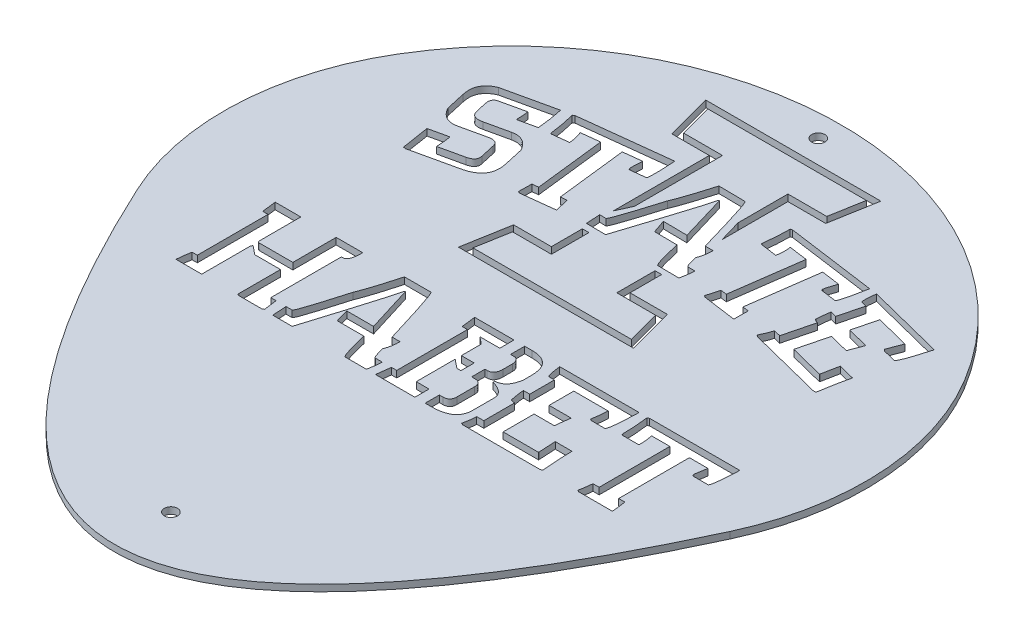
from build123d import *

# Parameters (mm, degrees)
BOSS_EXTRUDE1_DEPTH   = 1.27
FILLET1_R             = 50.8
HABET_TEXT_DEPTH      = 2.54
STATE_LOGO_1_DEPTH    = 2.54
STATE_LOGO_2_DEPTH    = 2.54
SKETCH5_R             = 1.27
MOUNT_HOLES_DEPTH     = 2.54
LETTER_TOUCHUPS_DEPTH = 1.27


with BuildPart() as part:
    # Sketch1 → Boss-Extrude1 (new body)
    with BuildSketch(Plane(origin=(0, 0, 0), x_dir=(1, 0, 0), z_dir=(0, 1, 0))):
        with BuildLine():
            ThreePointArc((105.41, 0), (41.91, 63.5), (-21.59, 0))
            add(Edge.make_bspline(
                [(-21.59, 0), (41.91, -152.4), (105.41, 0)],
                knots=[0, 0, 0, 1, 1, 1], degree=2))
        make_face()
    extrude(amount=BOSS_EXTRUDE1_DEPTH)

    # Fillet1
    fillet1_edges = [part.edges().sort_by_distance(p)[0] for p in [
        (105.41, 0.635, 0),
        (-21.59, 0.635, 0),
    ]]
    fillet(fillet1_edges, radius=FILLET1_R)

    # Sketch2 → HABET text (cut)
    with BuildSketch(Plane(origin=(0, 1.27, 0), x_dir=(1, 0, 0), z_dir=(0, 1, 0))):
        with BuildLine():
            Line((0.321789747, -3.776283493), (5.256736985, -3.776283493))
            Line((5.256736985, -3.776283493), (5.256736985, -11.769952021))
            add(Edge.make_bspline(
                [(5.256736985, -11.769952021), (5.276665661, -11.854790905), (5.324891876, -12.046060769), (5.511513222, -12.109993559), (5.591777333, -12.104992369)],
                knots=[0, 0, 0, 0, 0.531818286, 1, 1, 1, 1], degree=3))
            Line((5.591777333, -12.104992369), (12.056085216, -12.104992369))
            Line((12.056085216, -12.104992369), (12.056085216, -3.776283493))
            Line((12.056085216, -3.776283493), (17.164465104, -3.776283493))
            add(Edge.make_bspline(
                [(17.164465104, -3.776283493), (17.160143723, -4.174152873), (17.149808616, -4.734801136), (17.030648999, -5.415323619), (16.926195937, -5.80555091), (16.781923581, -6.109760812), (16.558088613, -6.405751765), (16.303749506, -6.506731746), (16.139635806, -6.503906087)],
                knots=[0, 0, 0, 0, 0.377825297, 0.528227417, 0.653887922, 0.759095955, 0.845793776, 1, 1, 1, 1], degree=3))
            Line((16.139635806, -6.503906087), (15.808537109, -6.503906087))
            Line((15.808537109, -6.503906087), (15.808537109, -20.098660898))
            Line((15.808537109, -20.098660898), (16.817599803, -20.098660898))
            add(Edge.make_bspline(
                [(16.817599803, -20.098660898), (16.81400749, -20.205888718), (16.841743547, -20.391521), (16.863462544, -20.676217018), (16.908505481, -20.9682663), (16.951195354, -21.314826269), (17.048718716, -21.880849288), (17.103583201, -22.335258896), (17.164465104, -22.652850842)],
                knots=[0, 0, 0, 0, 0.124227694, 0.217909618, 0.332038768, 0.467782146, 0.624074868, 1, 1, 1, 1], degree=3))
            Line((17.164465104, -22.652850842), (16.817599803, -22.826283493))
            Line((16.817599803, -22.826283493), (12.402950517, -22.826283493))
            add(Edge.make_bspline(
                [(12.402950517, -22.826283493), (12.317963623, -22.823811689), (12.097342761, -22.785025948), (12.05855702, -22.564405085), (12.056085216, -22.479418192)],
                knots=[0, 0, 0, 0, 0.5, 1, 1, 1, 1], degree=3))
            Line((12.056085216, -22.479418192), (12.056085216, -14.485749663))
            Line((12.056085216, -14.485749663), (7.121137978, -14.485749663))
            Line((7.121137978, -14.485749663), (5.430169636, -13.129821668))
            Line((5.430169636, -13.129821668), (5.256736985, -13.472745318))
            Line((5.256736985, -13.472745318), (5.256736985, -22.826283493))
            Line((5.256736985, -22.826283493), (0.321789747, -22.826283493))
            add(Edge.make_bspline(
                [(0.321789747, -22.826283493), (0.31645231, -22.671888101), (0.342834985, -22.424157171), (0.367003888, -22.067431584), (0.410908223, -21.746221323), (0.454724562, -21.385356188), (0.549119029, -20.83326951), (0.60736443, -20.397699329), (0.668655048, -20.098660898)],
                knots=[0, 0, 0, 0, 0.167857211, 0.271328623, 0.38963404, 0.521086911, 0.667536674, 1, 1, 1, 1], degree=3))
            Line((0.668655048, -20.098660898), (1.677717742, -20.098660898))
            Line((1.677717742, -20.098660898), (1.677717742, -6.503906087))
            Line((1.677717742, -6.503906087), (0.668655048, -6.503906087))
            add(Edge.make_bspline(
                [(0.668655048, -6.503906087), (0.608512822, -6.14398303), (0.553976204, -5.633282549), (0.456111496, -5.001477245), (0.413245992, -4.626120543), (0.368300279, -4.319582403), (0.347599895, -4.042730446), (0.319907176, -3.870322246), (0.321789747, -3.776283493)],
                knots=[0, 0, 0, 0, 0.397879084, 0.56002599, 0.697260921, 0.809964686, 0.897811149, 1, 1, 1, 1], degree=3))
        make_face()
        with BuildLine():
            Line((25.201491796, -3.788108446), (30.298046731, -3.788108446))
            add(Edge.make_bspline(
                [(30.298046731, -3.788108446), (30.366108127, -3.82479978), (30.436259495, -3.969338582), (30.548805268, -4.207612289), (30.672864093, -4.517281641), (30.821141387, -4.912112525), (31.000971498, -5.392688258), (31.193909996, -5.963520917), (31.417187781, -6.619626865), (31.658631144, -7.36469643), (31.933856353, -8.195801399), (32.222169546, -9.117039237), (32.538277645, -10.12494744), (32.882604334, -11.218169004), (33.380106407, -12.85532437), (33.77613151, -14.123269161), (34.034732019, -15.002105963)],
                knots=[0, 0, 0, 0, 0.018772946, 0.039326689, 0.067393185, 0.103005763, 0.146294354, 0.197354176, 0.255675461, 0.321892548, 0.395794966, 0.477496108, 0.566465293, 0.66343768, 0.76789845, 1, 1, 1, 1], degree=3))
            Line((34.034732019, -15.002105963), (35.564092665, -15.002105963))
            Line((35.564092665, -15.002105963), (35.564092665, -15.175538614))
            add(Edge.make_bspline(
                [(35.564092665, -15.175538614), (35.564803594, -15.648317662), (35.485635336, -16.575658132), (35.229848591, -17.470772068), (35.059561318, -17.891336255)],
                knots=[0, 0, 0, 0, 0.510453896, 1, 1, 1, 1], degree=3))
            add(Edge.make_bspline(
                [(35.059561318, -17.891336255), (35.135555264, -18.217900936), (35.265037045, -18.667915366), (35.431919653, -19.222203774), (35.54248004, -19.534768314), (35.641471172, -19.781208347), (35.748244999, -19.978992939), (35.832677069, -20.097695224), (35.910957966, -20.110485851)],
                knots=[0, 0, 0, 0, 0.415940519, 0.581562715, 0.71828315, 0.827951039, 0.909707124, 1, 1, 1, 1], degree=3))
            Line((35.910957966, -20.110485851), (37.266885961, -20.110485851))
            add(Edge.make_bspline(
                [(37.266885961, -20.110485851), (37.268121053, -20.261851817), (37.254175147, -20.507942151), (37.219517494, -20.861145434), (37.178731718, -21.18276862), (37.132628168, -21.54182206), (37.048659783, -22.093970448), (36.974167944, -22.525451161), (36.923962311, -22.826283493)],
                knots=[0, 0, 0, 0, 0.165637154, 0.269704192, 0.38854274, 0.52058799, 0.666056666, 1, 1, 1, 1], degree=3))
            Line((36.923962311, -22.826283493), (32.852236675, -22.826283493))
            add(Edge.make_bspline(
                [(32.852236675, -22.826283493), (32.797367163, -22.821835429), (32.728002071, -22.753372797), (32.645989727, -22.630805165), (32.569328789, -22.48407748), (32.4826095, -22.299312461), (32.392041375, -22.072858267), (32.299689146, -21.804776172), (32.196153456, -21.496316819), (32.087321891, -21.146303465), (31.967515127, -20.755585404), (31.846649167, -20.32286006), (31.720689432, -19.848131181), (31.58746859, -19.332877021), (31.389996836, -18.565652866), (31.249073667, -17.967581274), (31.149443379, -17.556295907)],
                knots=[0, 0, 0, 0, 0.027600123, 0.049889903, 0.079536148, 0.116114486, 0.159439305, 0.210267824, 0.268221252, 0.333985547, 0.40690073, 0.487456007, 0.574995553, 0.670392167, 0.772966334, 1, 1, 1, 1], degree=3))
            Line((31.149443379, -17.556295907), (26.052888444, -17.556295907))
            add(Edge.make_bspline(
                [(26.052888444, -17.556295907), (25.950743147, -17.249186625), (25.80298091, -16.813935152), (25.634254357, -16.260873111), (25.53982377, -15.917431262), (25.464659531, -15.621810041), (25.39560186, -15.323961222), (25.367328632, -15.121389448), (25.363099493, -15.002105963)],
                knots=[0, 0, 0, 0, 0.366211686, 0.519991781, 0.654155006, 0.769170486, 0.865109543, 1, 1, 1, 1], degree=3))
            Line((25.363099493, -15.002105963), (30.471479381, -15.002105963))
            Line((30.471479381, -15.002105963), (27.743856786, -6.16886574))
            Line((27.743856786, -6.16886574), (27.582249089, -6.16886574))
            add(Edge.make_bspline(
                [(27.582249089, -6.16886574), (27.582842019, -6.218363175), (27.563473491, -6.305845689), (27.538437338, -6.442900764), (27.500214022, -6.589193235), (27.458048659, -6.765510326), (27.406932983, -6.972186331), (27.342269106, -7.207919648), (27.273607029, -7.475614538), (27.188190335, -7.771469216), (27.100056016, -8.098389993), (26.995018229, -8.453355677), (26.88633136, -8.840497375), (26.763451685, -9.25642124), (26.632719359, -9.702948715), (26.496724867, -10.179534235), (26.344477603, -10.684268579), (26.189321484, -11.220153215), (26.017325454, -11.783985767), (25.841678335, -12.380085469), (25.651510128, -13.004808886), (25.455152846, -13.661053103), (25.245821924, -14.345060237), (25.02833695, -15.059603122), (24.805297133, -15.804155551), (24.567470018, -16.578946167), (24.318832483, -17.382142523), (24.069081924, -18.218437287), (23.797026556, -19.0792142), (23.527817539, -19.975621969), (23.144108404, -21.228148963), (22.84314523, -22.179969158), (22.647301852, -22.826283493)],
                knots=[0, 0, 0, 0, 0.008482174, 0.015421919, 0.024059449, 0.034567457, 0.046725771, 0.06081133, 0.076767196, 0.09443395, 0.113970549, 0.135220301, 0.158339433, 0.183390837, 0.210093577, 0.238665487, 0.26895253, 0.301108407, 0.334980225, 0.370720586, 0.408394613, 0.447719832, 0.488979062, 0.53188942, 0.576668045, 0.623163757, 0.671810766, 0.721825692, 0.773841637, 0.827658847, 0.883410324, 1, 1, 1, 1], degree=3))
            Line((22.647301852, -22.826283493), (18.910616563, -22.826283493))
            Line((18.910616563, -22.826283493), (18.910616563, -22.652850842))
            add(Edge.make_bspline(
                [(18.910616563, -22.652850842), (18.885058925, -22.332305289), (18.851980915, -21.878839793), (18.804082661, -21.310261094), (18.782652609, -20.965772751), (18.76052578, -20.675631453), (18.747854214, -20.396956696), (18.739665906, -20.214337694), (18.737183912, -20.110485851)],
                knots=[0, 0, 0, 0, 0.378522258, 0.535222019, 0.671642211, 0.784811358, 0.877725602, 1, 1, 1, 1], degree=3))
            Line((18.737183912, -20.110485851), (19.919679257, -20.110485851))
            add(Edge.make_bspline(
                [(19.919679257, -20.110485851), (19.985131767, -20.069760458), (20.057751116, -19.940739514), (20.162986768, -19.729744262), (20.274485416, -19.47499668), (20.391795464, -19.151533738), (20.536238129, -18.765288864), (20.692573984, -18.311462826), (20.86513219, -17.792168616), (21.05557133, -17.206547778), (21.258935676, -16.554333673), (21.479143791, -15.83507522), (21.721571587, -15.052077532), (21.972286722, -14.199798473), (22.341394187, -12.930557179), (22.631842004, -11.94668017), (22.820734502, -11.265420674)],
                knots=[0, 0, 0, 0, 0.023980153, 0.046648653, 0.076156427, 0.11318598, 0.157286101, 0.208716973, 0.267490156, 0.333211433, 0.406690053, 0.487124196, 0.5750428, 0.670202511, 0.77272806, 1, 1, 1, 1], degree=3))
            add(Edge.make_bspline(
                [(22.820734502, -11.265420674), (22.993716468, -10.871307767), (23.240489353, -10.216053846), (23.568097471, -9.26256965), (23.856307096, -8.384018568), (24.160161274, -7.391751957), (24.626608121, -5.851755586), (24.966292207, -4.63568599), (25.201491796, -3.788108446)],
                knots=[0, 0, 0, 0, 0.164380307, 0.267414189, 0.385207417, 0.517634643, 0.663904986, 1, 1, 1, 1], degree=3))
        make_face()
        with BuildLine():
            Line((38.666172118, -3.776283493), (46.236113149, -3.776283493))
            Line((46.236113149, -3.776283493), (46.236113149, -6.503906087))
            Line((46.236113149, -6.503906087), (42.402857407, -6.503906087))
            add(Edge.make_bspline(
                [(42.402857407, -6.503906087), (42.603197891, -6.658097959), (42.886058867, -6.872098254), (43.224794215, -7.150790756), (43.419614117, -7.311553615), (43.569426336, -7.445047376), (43.689377406, -7.560881316), (43.761928293, -7.634613354), (43.774552007, -7.686401432)],
                knots=[0, 0, 0, 0, 0.416957577, 0.584811766, 0.723250262, 0.83373621, 0.914955377, 1, 1, 1, 1], degree=3))
            Line((43.774552007, -7.686401432), (43.774552007, -11.427028372))
            Line((43.774552007, -11.427028372), (46.236113149, -11.427028372))
            Line((46.236113149, -11.427028372), (46.236113149, -13.981218316))
            Line((46.236113149, -13.981218316), (45.465520349, -13.981218316))
            Line((45.465520349, -13.981218316), (43.774552007, -12.62134867))
            Line((43.774552007, -12.62134867), (43.774552007, -20.098660898))
            Line((43.774552007, -20.098660898), (46.236113149, -20.098660898))
            Line((46.236113149, -20.098660898), (46.236113149, -22.826283493))
            Line((46.236113149, -22.826283493), (38.666172118, -22.826283493))
            add(Edge.make_bspline(
                [(38.666172118, -22.826283493), (38.664289547, -22.732244739), (38.691982266, -22.559836539), (38.71268265, -22.282984582), (38.757628363, -21.976446442), (38.800493867, -21.60108974), (38.898358575, -20.969284436), (38.952895193, -20.458583955), (39.01303742, -20.098660898)],
                knots=[0, 0, 0, 0, 0.102188851, 0.190035314, 0.302739079, 0.43997401, 0.602120916, 1, 1, 1, 1], degree=3))
            Line((39.01303742, -20.098660898), (40.022100114, -20.098660898))
            Line((40.022100114, -20.098660898), (40.022100114, -6.503906087))
            Line((40.022100114, -6.503906087), (39.01303742, -6.503906087))
            add(Edge.make_bspline(
                [(39.01303742, -6.503906087), (38.952895193, -6.14398303), (38.898358575, -5.633282549), (38.800493867, -5.001477245), (38.757628363, -4.626120543), (38.71268265, -4.319582403), (38.691982266, -4.042730446), (38.664289547, -3.870322246), (38.666172118, -3.776283493)],
                knots=[0, 0, 0, 0, 0.397879084, 0.56002599, 0.697260921, 0.809964686, 0.897811149, 1, 1, 1, 1], degree=3))
        make_face()
        with BuildLine():
            Line((53.806054179, -8.033266733), (53.806054179, -9.562627378))
            add(Edge.make_bspline(
                [(53.806054179, -9.562627378), (53.729787316, -9.991437992), (53.581838899, -10.601694806), (53.232504535, -11.312758399), (52.935570024, -11.728017089), (52.587002702, -12.052963631), (52.041944744, -12.36595725), (51.569661542, -12.453758376), (51.251864235, -12.447916019)],
                knots=[0, 0, 0, 0, 0.309204237, 0.440259692, 0.558793523, 0.66874782, 0.775023723, 1, 1, 1, 1], degree=3))
            Line((51.251864235, -12.447916019), (51.251864235, -12.79478132))
            add(Edge.make_bspline(
                [(51.251864235, -12.79478132), (51.660511252, -12.915074517), (52.237760161, -13.119511732), (52.906506332, -13.507425271), (53.295660249, -13.812737554), (53.604208108, -14.146182865), (53.895454555, -14.638342059), (53.979882628, -15.059070369), (53.97948683, -15.337146311)],
                knots=[0, 0, 0, 0, 0.318966866, 0.454552229, 0.576177643, 0.687424344, 0.792188109, 1, 1, 1, 1], degree=3))
            Line((53.97948683, -15.337146311), (53.97948683, -19.4206969))
            add(Edge.make_bspline(
                [(53.97948683, -19.4206969), (53.975334796, -19.686922898), (53.949824231, -20.079832687), (53.826875375, -20.575609944), (53.698719858, -20.911119158), (53.538972722, -21.220358244), (53.336055694, -21.499386815), (53.105758274, -21.757447544), (52.831550397, -21.983605326), (52.525562826, -22.18480727), (52.179362636, -22.353416046), (51.803921751, -22.504654968), (51.388172015, -22.62024729), (50.939815434, -22.717057806), (50.268572897, -22.796589175), (49.747373, -22.833803688), (49.387463242, -22.826283493)],
                knots=[0, 0, 0, 0, 0.122782394, 0.180144066, 0.23451605, 0.287817649, 0.339851427, 0.392950142, 0.446621134, 0.502991963, 0.56115177, 0.623604023, 0.689076562, 0.759544478, 0.834571594, 1, 1, 1, 1], degree=3))
            Line((49.387463242, -22.826283493), (48.213242928, -22.826283493))
            Line((48.213242928, -22.826283493), (48.213242928, -20.098660898))
            Line((48.213242928, -20.098660898), (48.871106942, -20.098660898))
            add(Edge.make_bspline(
                [(48.871106942, -20.098660898), (49.073427608, -20.105730071), (49.359023553, -20.062310635), (49.701333274, -19.922170953), (49.89417224, -19.765655681), (50.050743134, -19.571280999), (50.196742439, -19.230946083), (50.229854572, -18.94225259), (50.227034937, -18.742732903)],
                knots=[0, 0, 0, 0, 0.274588349, 0.390158281, 0.499895672, 0.609633064, 0.727569673, 1, 1, 1, 1], degree=3))
            Line((50.227034937, -18.742732903), (50.227034937, -15.337146311))
            add(Edge.make_bspline(
                [(50.227034937, -15.337146311), (50.227730573, -15.137091508), (50.199472963, -14.846449799), (50.049497263, -14.507944953), (49.894436998, -14.313816255), (49.700308299, -14.158755989), (49.361803453, -14.008780289), (49.071161744, -13.980522679), (48.871106942, -13.981218316)],
                knots=[0, 0, 0, 0, 0.274057167, 0.390310617, 0.5, 0.609689383, 0.725942833, 1, 1, 1, 1], degree=3))
            Line((48.871106942, -13.981218316), (48.299959254, -13.981218316))
            Line((48.299959254, -13.981218316), (48.299959254, -11.427028372))
            Line((48.299959254, -11.427028372), (48.697674291, -11.427028372))
            add(Edge.make_bspline(
                [(48.697674291, -11.427028372), (48.898802035, -11.422840356), (49.201194636, -11.389388524), (49.535522536, -11.195168397), (49.735343629, -11.004963801), (49.885647987, -10.756839191), (50.034686881, -10.331506442), (50.069347813, -9.974500347), (50.06542724, -9.724235075)],
                knots=[0, 0, 0, 0, 0.245182281, 0.352852037, 0.46020787, 0.573842407, 0.698393079, 1, 1, 1, 1], degree=3))
            Line((50.06542724, -9.724235075), (50.06542724, -7.859834082))
            add(Edge.make_bspline(
                [(50.06542724, -7.859834082), (50.066851791, -7.714077392), (50.044280442, -7.4988949), (49.952742771, -7.231882439), (49.856448589, -7.053608185), (49.737258938, -6.889018287), (49.534024088, -6.687700995), (49.347804749, -6.570040629), (49.214030591, -6.503906087)],
                knots=[0, 0, 0, 0, 0.257766199, 0.378193293, 0.496611434, 0.614573417, 0.736070202, 1, 1, 1, 1], degree=3))
            Line((49.214030591, -6.503906087), (48.299959254, -6.503906087))
            Line((48.299959254, -6.503906087), (48.299959254, -3.776283493))
            Line((48.299959254, -3.776283493), (49.72250359, -3.776283493))
            add(Edge.make_bspline(
                [(49.72250359, -3.776283493), (50.042771452, -3.774485163), (50.509606207, -3.805017383), (51.103758252, -3.918300209), (51.504714262, -4.031289309), (51.874060915, -4.181226252), (52.210708597, -4.367622639), (52.516610717, -4.585446496), (52.791695689, -4.835855534), (53.033299829, -5.120473333), (53.237698999, -5.440714523), (53.418675959, -5.788483587), (53.55727626, -6.175450171), (53.673374299, -6.592458925), (53.778362271, -7.214355673), (53.806662389, -7.699936697), (53.806054179, -8.033266733)],
                knots=[0, 0, 0, 0, 0.14198835, 0.206642877, 0.267847216, 0.326362386, 0.382935003, 0.438049631, 0.492470499, 0.547434115, 0.603008474, 0.660576772, 0.7208399, 0.784848432, 0.852261782, 1, 1, 1, 1], degree=3))
        make_face()
        with BuildLine():
            Line((55.063440896, -3.815700004), (70.337339096, -3.815700004))
            add(Edge.make_bspline(
                [(70.337339096, -3.815700004), (70.321198513, -4.28079399), (70.302393002, -4.955058678), (70.264116058, -5.822143799), (70.233236365, -6.402960565), (70.196462851, -6.937553441), (70.163118792, -7.426615145), (70.122165665, -7.867866501), (70.084693261, -8.262424711), (70.041032946, -8.610685571), (69.995557189, -8.913384525), (69.943476578, -9.169413355), (69.895157329, -9.379633486), (69.840376048, -9.54237335), (69.7780399, -9.680336446), (69.714076958, -9.759665593), (69.655433447, -9.763651587)],
                knots=[0, 0, 0, 0, 0.230352143, 0.333856093, 0.429597288, 0.518236752, 0.59909083, 0.672218473, 0.737576663, 0.795251807, 0.845932317, 0.889041456, 0.924531103, 0.952706592, 0.973649101, 1, 1, 1, 1], degree=3))
            Line((69.655433447, -9.763651587), (67.117010107, -9.763651587))
            Line((67.117010107, -9.763651587), (66.770144806, -9.590218936))
            add(Edge.make_bspline(
                [(66.770144806, -9.590218936), (66.824523996, -9.231975208), (66.896988836, -8.721081521), (66.982549795, -8.073107098), (67.027817811, -7.665399776), (67.069559153, -7.308388073), (67.102854574, -6.936709), (67.117992403, -6.682867621), (67.117010107, -6.531497645)],
                knots=[0, 0, 0, 0, 0.352908559, 0.50258996, 0.636562008, 0.752443971, 0.852661895, 1, 1, 1, 1], degree=3))
            Line((67.117010107, -6.531497645), (60.491094527, -6.531497645))
            Line((60.491094527, -6.531497645), (60.491094527, -11.277245628))
            Line((60.491094527, -11.277245628), (64.736252814, -11.277245628))
            add(Edge.make_bspline(
                [(64.736252814, -11.277245628), (64.682983146, -11.624775508), (64.618159524, -12.120598761), (64.532903106, -12.744547377), (64.48458008, -13.132070403), (64.45057536, -13.466120422), (64.415100028, -13.804516642), (64.400800221, -14.032190813), (64.401212466, -14.16647592)],
                knots=[0, 0, 0, 0, 0.362430854, 0.515490641, 0.649224206, 0.76500126, 0.86163784, 1, 1, 1, 1], degree=3))
            Line((64.401212466, -14.16647592), (60.491094527, -14.16647592))
            Line((60.491094527, -14.16647592), (60.491094527, -20.110485851))
            Line((60.491094527, -20.110485851), (67.290442758, -20.110485851))
            Line((67.290442758, -20.110485851), (67.290442758, -19.940994852))
            add(Edge.make_bspline(
                [(67.290442758, -19.940994852), (67.265094636, -19.536339208), (67.231559474, -18.963374665), (67.184050548, -18.244920588), (67.162168837, -17.807223866), (67.140516608, -17.43817572), (67.127683545, -17.083333235), (67.11938728, -16.852100524), (67.117010107, -16.720665864)],
                knots=[0, 0, 0, 0, 0.377135334, 0.533874761, 0.669730575, 0.784774336, 0.877729471, 1, 1, 1, 1], degree=3))
            Line((67.117010107, -16.720665864), (70.337339096, -16.720665864))
            add(Edge.make_bspline(
                [(70.337339096, -16.720665864), (70.335866009, -17.128064571), (70.34793792, -17.761580037), (70.383480138, -18.63524247), (70.424330618, -19.355142084), (70.470779139, -20.118670875), (70.551909163, -21.222746163), (70.629342284, -22.072210042), (70.680262745, -22.652850842)],
                knots=[0, 0, 0, 0, 0.20560279, 0.319753974, 0.441286115, 0.569515561, 0.705818734, 1, 1, 1, 1], degree=3))
            Line((70.680262745, -22.652850842), (70.337339096, -22.826283493))
            Line((70.337339096, -22.826283493), (55.410306197, -22.826283493))
            Line((55.410306197, -22.826283493), (55.063440896, -22.652850842))
            add(Edge.make_bspline(
                [(55.063440896, -22.652850842), (55.170710559, -22.174448053), (55.320856298, -21.330798966), (55.413264724, -20.477905476), (55.410306197, -20.110485851)],
                knots=[0, 0, 0, 0, 0.572014139, 1, 1, 1, 1], degree=3))
            Line((55.410306197, -20.110485851), (56.766234192, -20.110485851))
            Line((56.766234192, -20.110485851), (56.766234192, -14.16647592))
            add(Edge.make_bspline(
                [(56.766234192, -14.16647592), (56.642549853, -14.167661764), (56.467525822, -14.161735331), (56.254659594, -14.123718697), (56.132622252, -14.088386328), (56.035082831, -14.044688202), (55.950413036, -13.962075423), (55.907524589, -13.888410865), (55.914837544, -13.831435572)],
                knots=[0, 0, 0, 0, 0.371737379, 0.524225572, 0.647831931, 0.753726226, 0.840278573, 1, 1, 1, 1], degree=3))
            add(Edge.make_bspline(
                [(55.914837544, -13.831435572), (55.852961991, -13.540429263), (55.797029792, -13.118866722), (55.700942642, -12.588141092), (55.657634673, -12.248187062), (55.613225557, -11.949436743), (55.590105316, -11.629374379), (55.562781581, -11.410712703), (55.567972243, -11.277245628)],
                knots=[0, 0, 0, 0, 0.345623149, 0.494311896, 0.626972793, 0.744083917, 0.845332377, 1, 1, 1, 1], degree=3))
            Line((55.567972243, -11.277245628), (56.766234192, -11.277245628))
            Line((56.766234192, -11.277245628), (56.766234192, -6.531497645))
            Line((56.766234192, -6.531497645), (55.741404893, -6.531497645))
            add(Edge.make_bspline(
                [(55.741404893, -6.531497645), (55.653692794, -6.512577391), (55.572324593, -6.365996441), (55.475597695, -6.127519699), (55.398215015, -5.825833766), (55.309572419, -5.444749718), (55.197116905, -4.764209279), (55.111445563, -4.212780466), (55.063440896, -3.815700004)],
                knots=[0, 0, 0, 0, 0.085765201, 0.166448933, 0.274218893, 0.411848074, 0.579054395, 1, 1, 1, 1], degree=3))
        make_face()
        with BuildLine():
            Line((72.312106321, -3.776283493), (89.659313025, -3.776283493))
            add(Edge.make_bspline(
                [(89.659313025, -3.776283493), (89.638054236, -4.200643238), (89.612205379, -4.817251781), (89.562036349, -5.610549958), (89.526483425, -6.142665334), (89.492614083, -6.631681532), (89.452281912, -7.076938631), (89.412724892, -7.480297757), (89.37486714, -7.841981609), (89.332239653, -8.161543782), (89.284703771, -8.437301126), (89.237650432, -8.671495885), (89.192032834, -8.862281056), (89.146446969, -9.013498007), (89.087044771, -9.136235774), (89.035790502, -9.21437034), (88.981349027, -9.215762077)],
                knots=[0, 0, 0, 0, 0.229958817, 0.333972673, 0.430180738, 0.518585845, 0.599251218, 0.67212849, 0.73793261, 0.796058281, 0.84655955, 0.88937187, 0.925244122, 0.952902978, 0.97421148, 1, 1, 1, 1], degree=3))
            Line((88.981349027, -9.215762077), (86.253726433, -9.215762077))
            add(Edge.make_bspline(
                [(86.253726433, -9.215762077), (86.166901768, -9.218669197), (85.955699159, -9.176822596), (85.90562437, -8.968934686), (85.906861132, -8.884663381)],
                knots=[0, 0, 0, 0, 0.50925243, 1, 1, 1, 1], degree=3))
            add(Edge.make_bspline(
                [(85.906861132, -8.884663381), (85.901894473, -8.756439929), (85.928429774, -8.548247226), (85.952430876, -8.243996575), (85.995609671, -7.964833222), (86.04035452, -7.648663948), (86.134964043, -7.159851764), (86.192876251, -6.77127196), (86.253726433, -6.503906087)],
                knots=[0, 0, 0, 0, 0.159142885, 0.261079045, 0.380037088, 0.510802491, 0.658784665, 1, 1, 1, 1], degree=3))
            Line((86.253726433, -6.503906087), (82.686532143, -6.503906087))
            Line((82.686532143, -6.503906087), (82.686532143, -20.098660898))
            Line((82.686532143, -20.098660898), (83.872969139, -20.098660898))
            add(Edge.make_bspline(
                [(83.872969139, -20.098660898), (83.920888304, -20.460260783), (83.994067064, -20.968234097), (84.079874168, -21.601494708), (84.125691024, -21.976305202), (84.166675344, -22.283411356), (84.198232122, -22.559123102), (84.21531919, -22.732632235), (84.215892789, -22.826283493)],
                knots=[0, 0, 0, 0, 0.397950877, 0.559933232, 0.69719521, 0.809921186, 0.897936844, 1, 1, 1, 1], degree=3))
            Line((84.215892789, -22.826283493), (77.751584906, -22.826283493))
            Line((77.751584906, -22.826283493), (77.404719605, -22.652850842))
            add(Edge.make_bspline(
                [(77.404719605, -22.652850842), (77.458529165, -22.333986416), (77.530437264, -21.882162204), (77.616338254, -21.314385614), (77.661818892, -20.968398956), (77.703256056, -20.675818452), (77.735777452, -20.392232777), (77.752055797, -20.205456431), (77.751584906, -20.098660898)],
                knots=[0, 0, 0, 0, 0.376149658, 0.532208299, 0.667949726, 0.782077236, 0.87591975, 1, 1, 1, 1], degree=3))
            Line((77.751584906, -20.098660898), (78.938021901, -20.098660898))
            Line((78.938021901, -20.098660898), (78.938021901, -6.503906087))
            Line((78.938021901, -6.503906087), (75.370827612, -6.503906087))
            add(Edge.make_bspline(
                [(75.370827612, -6.503906087), (75.500221698, -6.875076877), (75.667040588, -7.777692254), (75.703011379, -8.693260646), (75.701926308, -9.215762077)],
                knots=[0, 0, 0, 0, 0.428461452, 1, 1, 1, 1], degree=3))
            Line((75.701926308, -9.215762077), (72.643205017, -9.215762077))
            add(Edge.make_bspline(
                [(72.643205017, -9.215762077), (72.557122545, -9.222332745), (72.358432891, -9.169435507), (72.305535653, -8.970745854), (72.312106321, -8.884663381)],
                knots=[0, 0, 0, 0, 0.5, 1, 1, 1, 1], degree=3))
            add(Edge.make_bspline(
                [(72.312106321, -8.884663381), (72.317177589, -8.082228245), (72.24421198, -6.432820032), (72.0829856, -4.789809224), (71.96524102, -3.949716143)],
                knots=[0, 0, 0, 0, 0.486078456, 1, 1, 1, 1], degree=3))
            Line((71.96524102, -3.949716143), (72.312106321, -3.776283493))
        make_face()
    extrude(amount=-HABET_TEXT_DEPTH, mode=Mode.SUBTRACT)

    # Sketch3 → State Logo 1 (cut)
    with BuildSketch(Plane(origin=(0, 1.27, 0), x_dir=(1, 0, 0), z_dir=(0, 1, 0))):
        with BuildLine():
            Line((12.446854571, 38.961215903), (12.486271082, 38.791724903))
            add(Edge.make_bspline(
                [(12.486271082, 38.791724903), (12.568054996, 38.408640086), (12.734136266, 37.630697205), (12.931518445, 36.434916188), (13.099299654, 35.196826666), (13.178971137, 34.355066351), (13.219418196, 33.927727386)],
                knots=[0, 0, 0, 0, 0.001175009, 0.002386129, 0.00363483, 0.004922453, 0.004922453, 0.004922453, 0.004922453], degree=3))
            Line((13.219418196, 33.927727386), (9.754706837, 33.155163761))
            add(Edge.make_bspline(
                [(9.754706837, 33.155163761), (9.754511612, 33.395677482), (9.754143311, 33.849420571), (9.716907988, 34.489717139), (9.664186577, 35.04868132), (9.599315002, 35.390416807), (9.569449233, 35.547746008)],
                knots=[0, 0, 0, 0, 0.000721365, 0.001360897, 0.001923726, 0.002403912, 0.002403912, 0.002403912, 0.002403912], degree=3))
            Line((9.569449233, 35.547746008), (4.953775738, 34.515033408))
            add(Edge.make_bspline(
                [(4.953775738, 34.515033408), (4.86308099, 34.491247743), (4.690817195, 34.446069725), (4.4630332, 34.321274324), (4.283749106, 34.154190456), (4.149782175, 33.949170735), (4.07296518, 33.702988967), (4.037255252, 33.42281605), (4.05798446, 33.104013661), (4.099813079, 32.882760428), (4.122087346, 32.764940298)],
                knots=[0, 0, 0, 0, 0.000280523, 0.000532819, 0.000769876, 0.001009313, 0.001258605, 0.001536792, 0.001852518, 0.00221216, 0.00221216, 0.00221216, 0.00221216], degree=3))
            Line((4.122087346, 32.764940298), (4.563552274, 30.786231421))
            add(Edge.make_bspline(
                [(4.563552274, 30.786231421), (4.59780446, 30.656924665), (4.662696075, 30.41194981), (4.835584335, 30.089204372), (5.057563124, 29.83076392), (5.333883725, 29.639538609), (5.66380354, 29.52217274), (6.039743573, 29.469248807), (6.464503652, 29.483574917), (6.757060584, 29.541416318), (6.912776359, 29.572202867)],
                knots=[0, 0, 0, 0, 0.000400209, 0.000758205, 0.001087846, 0.001413671, 0.001754139, 0.002128741, 0.002546723, 0.003022358, 0.003022358, 0.003022358, 0.003022358], degree=3))
            Line((6.912776359, 29.572202867), (11.374725458, 30.569440608))
            add(Edge.make_bspline(
                [(11.374725458, 30.569440608), (11.574977827, 30.60693929), (11.964237354, 30.679830908), (12.546001776, 30.66576328), (13.094978224, 30.554339066), (13.610720907, 30.342738269), (14.090338803, 30.025537196), (14.539813911, 29.615668925), (14.947039981, 29.097448202), (15.179093651, 28.705381782), (15.300610002, 28.500073755)],
                knots=[0, 0, 0, 0, 0.000609849, 0.001185451, 0.001732759, 0.002282475, 0.002846613, 0.003449286, 0.004099957, 0.004815255, 0.004815255, 0.004815255, 0.004815255], degree=3))
            Line((15.300610002, 28.500073755), (16.148064999, 24.712147002))
            add(Edge.make_bspline(
                [(16.148064999, 24.712147002), (16.182486467, 24.544440413), (16.249073708, 24.220017322), (16.298971178, 23.738447881), (16.313540121, 23.282231182), (16.282698652, 22.848757271), (16.207850598, 22.441771767), (16.092778979, 22.057882323), (15.936093262, 21.697796431), (15.731610387, 21.364752539), (15.489900183, 21.053632123), (15.203051824, 20.770542059), (14.878280185, 20.505977596), (14.503544817, 20.277405492), (14.094354761, 20.062608767), (13.641529597, 19.877562028), (13.146248147, 19.72097365), (12.799516086, 19.635911524), (12.620287221, 19.59194216)],
                knots=[0, 0, 0, 0, 0.000513323, 0.000993008, 0.001450392, 0.001881188, 0.002294028, 0.002689315, 0.003081127, 0.003468474, 0.003858777, 0.004260129, 0.004675033, 0.005112486, 0.005574383, 0.006060422, 0.00657774, 0.007131272, 0.007131272, 0.007131272, 0.007131272], degree=3))
            Line((12.620287221, 19.59194216), (3.877704974, 17.63688319))
            Line((3.877704974, 17.63688319), (3.503248115, 17.731482818))
            add(Edge.make_bspline(
                [(3.503248115, 17.731482818), (3.450693129, 18.087545403), (3.351009465, 18.762907079), (3.209997356, 19.718231942), (3.08331854, 20.559041478), (2.973804503, 21.284630213), (2.877189363, 21.895967347), (2.787122989, 22.391569955), (2.724655443, 22.775272103), (2.678725965, 22.991072842), (2.659734769, 23.080303426)],
                knots=[0, 0, 0, 0, 0.001079761, 0.002048036, 0.002897029, 0.003630643, 0.004249494, 0.004753656, 0.005141824, 0.005415478, 0.005415478, 0.005415478, 0.005415478], degree=3))
            Line((2.659734769, 23.080303426), (6.282112175, 23.892283563))
            add(Edge.make_bspline(
                [(6.282112175, 23.892283563), (6.292842312, 23.8345125), (6.317418069, 23.702196617), (6.353309084, 23.476364451), (6.3863868, 23.197292523), (6.427505254, 22.865218143), (6.465794818, 22.478764141), (6.50538503, 22.037293545), (6.543324326, 21.541724226), (6.571067407, 21.193558033), (6.585619313, 21.010936573)],
                knots=[0, 0, 0, 0, 0.000176276, 0.000403734, 0.00068583, 0.001019267, 0.001407555, 0.001850776, 0.002348985, 0.002898588, 0.002898588, 0.002898588, 0.002898588], degree=3))
            Line((6.585619313, 21.010936573), (11.201292808, 22.043649174))
            add(Edge.make_bspline(
                [(11.201292808, 22.043649174), (11.329956072, 22.075362339), (11.571374288, 22.134867557), (11.894588966, 22.275196317), (12.162316722, 22.438209371), (12.365240296, 22.640141588), (12.509347154, 22.871806955), (12.589109174, 23.134958332), (12.603290968, 23.427801283), (12.567987252, 23.625983136), (12.549337501, 23.730675866)],
                knots=[0, 0, 0, 0, 0.000396876, 0.00074468, 0.001053037, 0.001331754, 0.001595403, 0.001863464, 0.002147701, 0.002466, 0.002466, 0.002466, 0.002466], degree=3))
            Line((12.549337501, 23.730675866), (11.922614968, 26.537131483))
            add(Edge.make_bspline(
                [(11.922614968, 26.537131483), (11.895256058, 26.639822209), (11.843153043, 26.835389083), (11.702922238, 27.092796298), (11.520691942, 27.298872704), (11.291930098, 27.448034221), (11.02064259, 27.543733513), (10.708236017, 27.578240917), (10.356022763, 27.566365943), (10.112886442, 27.5172071), (9.983322603, 27.491011061)],
                knots=[0, 0, 0, 0, 0.000317908, 0.000605433, 0.00087058, 0.001135141, 0.001415664, 0.001725629, 0.002072696, 0.002468631, 0.002468631, 0.002468631, 0.002468631], degree=3))
            Line((9.983322603, 27.491011061), (5.198158109, 26.4228236))
            add(Edge.make_bspline(
                [(5.198158109, 26.4228236), (4.997898966, 26.385251302), (4.609920338, 26.312459377), (4.028317751, 26.327131907), (3.479008032, 26.437178754), (2.962394046, 26.649802769), (2.482481926, 26.965294002), (2.037459779, 27.379425857), (1.624901256, 27.89219192), (1.395801985, 28.286412539), (1.276215216, 28.492190453)],
                knots=[0, 0, 0, 0, 0.000609849, 0.00118151, 0.00173268, 0.002282395, 0.002846533, 0.003446299, 0.004099437, 0.004812658, 0.004812658, 0.004812658, 0.004812658], degree=3))
            Line((1.276215216, 28.492190453), (0.42876022, 32.280117206))
            add(Edge.make_bspline(
                [(0.42876022, 32.280117206), (0.401997882, 32.412518581), (0.349783606, 32.670838385), (0.303395249, 33.054175679), (0.280994418, 33.421707878), (0.294447099, 33.774970919), (0.330959593, 34.113310789), (0.403919769, 34.43483543), (0.501765674, 34.742077042), (0.633033993, 35.031036969), (0.785837791, 35.3094397), (0.979724258, 35.562714077), (1.189934012, 35.810915453), (1.439286253, 36.035670087), (1.714104902, 36.246659099), (2.015012946, 36.446781332), (2.349432467, 36.623357686), (2.585494704, 36.7277401), (2.707034583, 36.781482818)],
                knots=[0, 0, 0, 0, 0.00040509, 0.000790345, 0.001157448, 0.001508454, 0.00184972, 0.002176782, 0.002495885, 0.002815256, 0.003127668, 0.003446162, 0.003770241, 0.004102207, 0.004450681, 0.004809263, 0.00518488, 0.005583513, 0.005583513, 0.005583513, 0.005583513], degree=3))
            Line((2.707034583, 36.781482818), (12.446854571, 38.961215903))
        make_face()
        with BuildLine():
            Line((14.730815335, 39.461313956), (31.916414342, 41.447906135))
            add(Edge.make_bspline(
                [(31.916414342, 41.447906135), (31.930852935, 41.229801304), (31.958858422, 40.806759254), (31.999698686, 40.193333944), (32.029849432, 39.620316286), (32.058742285, 39.089632621), (32.078891786, 38.600833276), (32.089609969, 38.154023775), (32.098876505, 37.750688459), (32.099592296, 37.387943376), (32.09064708, 37.068665919), (32.081107415, 36.789869035), (32.060323998, 36.55325209), (32.038999041, 36.357182971), (32.009889903, 36.20100292), (31.97110194, 36.091411406), (31.931086153, 36.010708418), (31.887496106, 35.992469043), (31.869114529, 35.984777643)],
                knots=[0, 0, 0, 0, 0.000655749, 0.001271909, 0.001844317, 0.002377155, 0.002866317, 0.003311881, 0.003717947, 0.004076637, 0.004399949, 0.004676118, 0.004913437, 0.005111933, 0.005268858, 0.005386052, 0.005465864, 0.005524062, 0.005524062, 0.005524062, 0.005524062], degree=3))
            Line((31.869114529, 35.984777643), (29.165141841, 35.669445551))
            add(Edge.make_bspline(
                [(29.165141841, 35.669445551), (29.113423268, 35.666448992), (29.021320335, 35.661112576), (28.894382306, 35.712828365), (28.807219267, 35.817822999), (28.79394836, 35.908147298), (28.786743331, 35.957186085)],
                knots=[0, 0, 0, 0, 0.000153775, 0.00027385, 0.000396991, 0.000543258, 0.000543258, 0.000543258, 0.000543258], degree=3))
            add(Edge.make_bspline(
                [(28.786743331, 35.957186085), (28.780864565, 36.014951425), (28.76792862, 36.14206131), (28.761569449, 36.35131699), (28.763018083, 36.597051154), (28.765816568, 36.878313681), (28.778385656, 37.196335033), (28.79957957, 37.550942005), (28.821418927, 37.94269424), (28.842697777, 38.215788608), (28.8537514, 38.357651635)],
                knots=[0, 0, 0, 0, 0.000174148, 0.000383204, 0.000627586, 0.000911413, 0.001226966, 0.001582262, 0.001977136, 0.002404001, 0.002404001, 0.002404001, 0.002404001], degree=3))
            Line((28.8537514, 38.357651635), (25.322031971, 37.951661566))
            Line((25.322031971, 37.951661566), (26.882925826, 24.479097941))
            Line((26.882925826, 24.479097941), (28.057537868, 24.61311408))
            add(Edge.make_bspline(
                [(28.057537868, 24.61311408), (28.106533509, 24.426640911), (28.198935025, 24.074968733), (28.323179702, 23.578810806), (28.434531998, 23.149763061), (28.526425026, 22.786097745), (28.59617851, 22.485924296), (28.652489105, 22.251292194), (28.688680498, 22.080296541), (28.705415264, 21.987999699), (28.711851959, 21.952499555)],
                knots=[0, 0, 0, 0, 0.000578403, 0.001090818, 0.001534407, 0.001908199, 0.002216052, 0.002458904, 0.002632067, 0.002740301, 0.002740301, 0.002740301, 0.002740301], degree=3))
            Line((28.711851959, 21.952499555), (22.306668843, 21.211469139))
            Line((22.306668843, 21.211469139), (21.944036937, 21.341543627))
            add(Edge.make_bspline(
                [(21.944036937, 21.341543627), (21.952615616, 21.511007034), (21.968904704, 21.832782049), (21.981322432, 22.288932255), (22.000416969, 22.692090478), (22.007131381, 23.04038407), (22.010923557, 23.334673134), (22.013562139, 23.573936171), (22.004401258, 23.760474949), (21.997976501, 23.86683423), (21.995278402, 23.911500176)],
                knots=[0, 0, 0, 0, 0.000509023, 0.000966526, 0.001368883, 0.001719779, 0.002011488, 0.002251928, 0.002437354, 0.002571602, 0.002571602, 0.002571602, 0.002571602], degree=3))
            Line((21.995278402, 23.911500176), (23.165948793, 24.049457966))
            Line((23.165948793, 24.049457966), (21.605054938, 37.522021591))
            Line((21.605054938, 37.522021591), (18.073335509, 37.112089872))
            add(Edge.make_bspline(
                [(18.073335509, 37.112089872), (18.145398302, 36.946590967), (18.302214117, 36.586448862), (18.470021496, 35.972140589), (18.61722654, 35.254737628), (18.681536209, 34.738530223), (18.715824646, 34.4633003)],
                knots=[0, 0, 0, 0, 0.000540926, 0.001177109, 0.001905302, 0.002737, 0.002737, 0.002737, 0.002737], degree=3))
            Line((18.715824646, 34.4633003), (15.684694913, 34.112493348))
            add(Edge.make_bspline(
                [(15.684694913, 34.112493348), (15.635738139, 34.109908118), (15.546488653, 34.105195175), (15.421723835, 34.154855039), (15.339331868, 34.262421651), (15.32562976, 34.351449114), (15.318121357, 34.400233882)],
                knots=[0, 0, 0, 0, 0.000145894, 0.000265969, 0.000386625, 0.000532892, 0.000532892, 0.000532892, 0.000532892], degree=3))
            add(Edge.make_bspline(
                [(15.318121357, 34.400233882), (15.268688769, 34.792235257), (15.168550638, 35.586332571), (14.95777079, 36.785442469), (14.714020552, 38.013479252), (14.510753817, 38.835332211), (14.407599941, 39.252406445)],
                knots=[0, 0, 0, 0, 0.001185146, 0.002400812, 0.003651564, 0.00494031, 0.00494031, 0.00494031, 0.00494031], degree=3))
            Line((14.407599941, 39.252406445), (14.730815335, 39.461313956))
        make_face()
        with BuildLine():
            Line((40.287212346, 41.570227086), (45.38376728, 41.507160668))
            add(Edge.make_bspline(
                [(45.38376728, 41.507160668), (45.403181323, 41.49362572), (45.465607515, 41.45010386), (45.529395092, 41.300998176), (45.630657236, 41.083978621), (45.749890635, 40.773560419), (45.896272995, 40.378844866), (46.064987316, 39.895197657), (46.252642952, 39.322748884), (46.466471611, 38.663456358), (46.701465004, 37.915376722), (46.962951638, 37.08055083), (47.24073173, 36.155447611), (47.54980687, 35.145043061), (47.876578579, 34.045182339), (48.221138091, 32.857298832), (48.598883643, 31.584558996), (48.851783893, 30.704606379), (48.982494779, 30.249804988)],
                knots=[0, 0, 0, 0, 7.0179e-05, 0.000225662, 0.000467392, 0.000798232, 0.001218513, 0.001732109, 0.00233415, 0.003025963, 0.003811331, 0.00468652, 0.005650389, 0.006709021, 0.007856373, 0.009092475, 0.010419554, 0.011839183, 0.011839183, 0.011839183, 0.011839183], degree=3))
            Line((48.982494779, 30.249804988), (50.511855424, 30.230096733))
            Line((50.511855424, 30.230096733), (50.511855424, 30.056664082))
            add(Edge.make_bspline(
                [(50.511855424, 30.056664082), (50.503828525, 29.817075962), (50.487960369, 29.343440777), (50.375730777, 28.650191382), (50.21557054, 27.981343079), (50.05276783, 27.558778864), (49.971849217, 27.348749743)],
                knots=[0, 0, 0, 0, 0.000718463, 0.001420309, 0.002102886, 0.002777416, 0.002777416, 0.002777416, 0.002777416], degree=3))
            add(Edge.make_bspline(
                [(49.971849217, 27.348749743), (50.014588849, 27.175155654), (50.094741465, 26.849602537), (50.215811577, 26.397259539), (50.329926482, 26.013155533), (50.434552915, 25.698793369), (50.530635793, 25.451151126), (50.620857381, 25.27709851), (50.69949616, 25.154389257), (50.769357204, 25.127788321), (50.795654307, 25.117775193)],
                knots=[0, 0, 0, 0, 0.000536311, 0.001005781, 0.001404843, 0.00173765, 0.002001152, 0.00219685, 0.00233413, 0.002416999, 0.002416999, 0.002416999, 0.002416999], degree=3))
            Line((50.795654307, 25.117775193), (52.151582302, 25.102008589))
            add(Edge.make_bspline(
                [(52.151582302, 25.102008589), (52.149657793, 25.03233096), (52.145476269, 24.880937189), (52.122457398, 24.635471787), (52.098091181, 24.35229209), (52.050446315, 24.032479229), (52.001650148, 23.674569218), (51.937028508, 23.279271259), (51.862835897, 22.846859478), (51.806453967, 22.546429201), (51.777125443, 22.390152598)],
                knots=[0, 0, 0, 0, 0.000209056, 0.000454232, 0.000739369, 0.001061573, 0.001423905, 0.001823084, 0.002263086, 0.002740091, 0.002740091, 0.002740091, 0.002740091], degree=3))
            Line((51.777125443, 22.390152598), (47.705399807, 22.437452412))
            add(Edge.make_bspline(
                [(47.705399807, 22.437452412), (47.684854432, 22.442497948), (47.633974175, 22.45499313), (47.569094418, 22.529116598), (47.500029005, 22.635264597), (47.426935337, 22.784015715), (47.342743148, 22.969419923), (47.259311889, 23.198828126), (47.162477475, 23.466979396), (47.067050696, 23.778600095), (46.958262766, 24.129643783), (46.850731052, 24.523731032), (46.730798338, 24.956510299), (46.609965833, 25.431550654), (46.47866087, 25.94728225), (46.345632933, 26.505962997), (46.208493153, 27.105590905), (46.114273494, 27.518237662), (46.065672929, 27.731089904)],
                knots=[0, 0, 0, 0, 6.2323e-05, 0.000154342, 0.000282248, 0.000446194, 0.000649103, 0.000893613, 0.001177849, 0.00150446, 0.001871054, 0.002280379, 0.002729797, 0.003218323, 0.003750811, 0.004326346, 0.004941155, 0.005596145, 0.005596145, 0.005596145, 0.005596145], degree=3))
            Line((46.065672929, 27.731089904), (40.969117994, 27.790214672))
            add(Edge.make_bspline(
                [(40.969117994, 27.790214672), (40.917709931, 27.953082163), (40.820390202, 28.261403838), (40.684441873, 28.70100917), (40.571948119, 29.093099924), (40.473938982, 29.437460571), (40.404192168, 29.735275321), (40.352626456, 29.98478508), (40.315902925, 30.185655), (40.312379638, 30.304881783), (40.310862252, 30.356229569)],
                knots=[0, 0, 0, 0, 0.000512369, 0.000969957, 0.001380363, 0.001736095, 0.002043948, 0.002297504, 0.002500986, 0.002654912, 0.002654912, 0.002654912, 0.002654912], degree=3))
            Line((40.310862252, 30.356229569), (45.419242141, 30.293163151))
            Line((45.419242141, 30.293163151), (42.798044127, 39.157936584))
            Line((42.798044127, 39.157936584), (42.63643643, 39.161878235))
            add(Edge.make_bspline(
                [(42.63643643, 39.161878235), (42.635545492, 39.142122556), (42.633329363, 39.092982077), (42.615231485, 39.006219898), (42.585763806, 38.890115129), (42.552369188, 38.743728062), (42.507433274, 38.566417265), (42.453515602, 38.359766062), (42.385001075, 38.124045843), (42.311075184, 37.857988293), (42.222623933, 37.563246392), (42.130340748, 37.23633889), (42.022094225, 36.882515484), (41.908830767, 36.49815384), (41.781054216, 36.085173323), (41.649084108, 35.640061423), (41.502158605, 35.166070815), (41.343818755, 34.662159657), (41.178989664, 34.127183249), (41.006275284, 33.56289821), (40.820335442, 32.970542004), (40.622119059, 32.348533564), (40.419294616, 31.694443377), (40.200994785, 31.013429545), (39.976282879, 30.300900411), (39.740726322, 29.559987503), (39.495230822, 28.787360015), (39.24014317, 27.987266575), (38.975008258, 27.15549204), (38.699327185, 26.295242827), (38.416549882, 25.403682912), (38.120123157, 24.484218308), (37.81187342, 23.534963383), (37.605367853, 22.890809375), (37.500464984, 22.563585249)],
                knots=[0, 0, 0, 0, 5.9256e-05, 0.000147394, 0.000264985, 0.000418911, 0.000597681, 0.000813754, 0.001059563, 0.001334067, 0.001642147, 0.001982707, 0.002353075, 0.002752137, 0.003184804, 0.003649935, 0.004144907, 0.0046735, 0.005234545, 0.00582428, 0.006443872, 0.007097093, 0.007782759, 0.008498296, 0.009242517, 0.010024128, 0.010830665, 0.011674593, 0.012543447, 0.013449693, 0.014384621, 0.015349432, 0.016347884, 0.017378767, 0.017378767, 0.017378767, 0.017378767], degree=3))
            Line((37.500464984, 22.563585249), (33.763779695, 22.606943412))
            Line((33.763779695, 22.606943412), (33.767721346, 22.780376062))
            add(Edge.make_bspline(
                [(33.767721346, 22.780376062), (33.756025134, 22.949875364), (33.733902212, 23.270476577), (33.700578618, 23.724880274), (33.678180847, 24.125784583), (33.658446921, 24.471327853), (33.642024478, 24.761675748), (33.631037123, 24.998188143), (33.620577886, 25.180759185), (33.62150494, 25.284630776), (33.621880254, 25.326682704)],
                knots=[0, 0, 0, 0, 0.000509709, 0.000964094, 0.001366838, 0.001714263, 0.002002435, 0.002239229, 0.002424654, 0.002550787, 0.002550787, 0.002550787, 0.002550787], degree=3))
            Line((33.621880254, 25.326682704), (34.804375598, 25.310916099))
            add(Edge.make_bspline(
                [(34.804375598, 25.310916099), (34.826385934, 25.328411817), (34.885723789, 25.375578673), (34.958311434, 25.503809203), (35.052191476, 25.689249391), (35.166945705, 25.941088091), (35.288756423, 26.263618895), (35.441495514, 26.646041863), (35.600584448, 27.099974263), (35.783388011, 27.616249956), (35.972999777, 28.20345916), (36.193076417, 28.850133918), (36.419733727, 29.567717665), (36.668222777, 30.349005195), (36.932429158, 31.197753956), (37.212370841, 32.112202363), (37.507024011, 33.094366834), (37.710636561, 33.771028502), (37.815797075, 34.120506416)],
                knots=[0, 0, 0, 0, 8.3801e-05, 0.000225919, 0.000433932, 0.000710887, 0.001054173, 0.001468478, 0.001946004, 0.00249699, 0.003111496, 0.003797048, 0.004546221, 0.005368979, 0.00625663, 0.007212958, 0.008237984, 0.009332855, 0.009332855, 0.009332855, 0.009332855], degree=3))
            add(Edge.make_bspline(
                [(37.815797075, 34.120506416), (37.893025281, 34.301403238), (38.06155799, 34.696168744), (38.312651647, 35.349937135), (38.587682553, 36.115081957), (38.885902579, 36.991595148), (39.204297347, 37.979116254), (39.547401409, 39.0761973), (39.914052539, 40.284618009), (40.15937528, 41.129803202), (40.287212346, 41.570227086)],
                knots=[0, 0, 0, 0, 0.000590038, 0.001287621, 0.002100557, 0.00302919, 0.004065035, 0.00521322, 0.006477612, 0.007853406, 0.007853406, 0.007853406, 0.007853406], degree=3))
        make_face()
        with BuildLine():
            Line((54.700867635, 41.33750381), (71.886466642, 38.952804866))
            add(Edge.make_bspline(
                [(71.886466642, 38.952804866), (71.845794797, 38.736002518), (71.767397624, 38.31810431), (71.652753307, 37.712221461), (71.544065569, 37.147933947), (71.432411834, 36.627111373), (71.330449373, 36.147142561), (71.232386092, 35.710790375), (71.138212899, 35.316472252), (71.047265146, 34.964362106), (70.961413128, 34.653978785), (70.879886753, 34.385373493), (70.799917324, 34.161385186), (70.731702744, 33.976454687), (70.660512167, 33.835681313), (70.600290559, 33.734014339), (70.53807801, 33.667106186), (70.490543396, 33.661445445), (70.47141388, 33.659167373)],
                knots=[0, 0, 0, 0, 0.000661751, 0.001275562, 0.001849921, 0.002385652, 0.002873478, 0.003321961, 0.00372732, 0.004089651, 0.004412891, 0.004693414, 0.004931517, 0.00512622, 0.005284868, 0.005401863, 0.005485664, 0.005542099, 0.005542099, 0.005542099, 0.005542099], degree=3))
            Line((70.47141388, 33.659167373), (67.767441192, 34.033624232))
            add(Edge.make_bspline(
                [(67.767441192, 34.033624232), (67.717195446, 34.042475469), (67.624978602, 34.05872029), (67.516021419, 34.144435549), (67.459165978, 34.26868481), (67.464802449, 34.358894648), (67.467875705, 34.408081092)],
                knots=[0, 0, 0, 0, 0.000151074, 0.000277268, 0.00039895, 0.000544844, 0.000544844, 0.000544844, 0.000544844], degree=3))
            add(Edge.make_bspline(
                [(67.467875705, 34.408081092), (67.476136567, 34.466073768), (67.494292412, 34.593530942), (67.546053854, 34.797192182), (67.602573755, 35.036372111), (67.685107316, 35.306674079), (67.773134298, 35.613965888), (67.881450525, 35.953733681), (68.00257887, 36.327240967), (68.091572113, 36.586632505), (68.1379564, 36.721830316)],
                knots=[0, 0, 0, 0, 0.000175614, 0.000385966, 0.000629744, 0.000912913, 0.001233449, 0.001588745, 0.001982634, 0.002411423, 0.002411423, 0.002411423, 0.002411423], degree=3))
            Line((68.1379564, 36.721830316), (64.606236971, 37.210595058))
            Line((64.606236971, 37.210595058), (62.737894327, 23.738031433))
            Line((62.737894327, 23.738031433), (63.912506369, 23.576423736))
            add(Edge.make_bspline(
                [(63.912506369, 23.576423736), (63.912558037, 23.38328244), (63.912655397, 23.019335918), (63.912017567, 22.506926073), (63.913981305, 22.061497859), (63.908252347, 21.684441118), (63.906533817, 21.37427905), (63.897591459, 21.132576568), (63.891204252, 20.957712603), (63.883794087, 20.864556038), (63.88097316, 20.829092885)],
                knots=[0, 0, 0, 0, 0.000579423, 0.001091837, 0.001537244, 0.001915663, 0.002223137, 0.002467647, 0.002641258, 0.002747974, 0.002747974, 0.002747974, 0.002747974], degree=3))
            Line((63.88097316, 20.829092885), (57.475790044, 21.715964394))
            Line((57.475790044, 21.715964394), (57.156516301, 21.932755207))
            add(Edge.make_bspline(
                [(57.156516301, 21.932755207), (57.206938209, 22.095527943), (57.302754488, 22.404843444), (57.430728669, 22.84470946), (57.545105398, 23.232272871), (57.646264164, 23.565838703), (57.720671541, 23.851899101), (57.778110897, 24.086139956), (57.825094064, 24.267777304), (57.842870968, 24.372531261), (57.850246903, 24.41599543)],
                knots=[0, 0, 0, 0, 0.0005112, 0.000971429, 0.001374269, 0.0017235, 0.002017014, 0.002260792, 0.00244722, 0.002579427, 0.002579427, 0.002579427, 0.002579427], degree=3))
            Line((57.850246903, 24.41599543), (59.020917294, 24.254387733))
            Line((59.020917294, 24.254387733), (60.889259938, 37.726951358))
            Line((60.889259938, 37.726951358), (57.357540509, 38.215716101))
            add(Edge.make_bspline(
                [(57.357540509, 38.215716101), (57.386916248, 38.036122564), (57.450497112, 37.64741022), (57.453047938, 37.008902333), (57.420828063, 36.276776894), (57.353831128, 35.759723864), (57.318123998, 35.484151855)],
                knots=[0, 0, 0, 0, 0.000545175, 0.001179976, 0.001910044, 0.002743179, 0.002743179, 0.002743179, 0.002743179], degree=3))
            Line((57.318123998, 35.484151855), (54.286994265, 35.901966877))
            add(Edge.make_bspline(
                [(54.286994265, 35.901966877), (54.237868524, 35.910735834), (54.147666482, 35.926836921), (54.043653277, 36.014269985), (53.985616437, 36.136837352), (53.994442283, 36.227175506), (53.999253731, 36.276423736)],
                knots=[0, 0, 0, 0, 0.000147272, 0.000270413, 0.000392095, 0.000537936, 0.000537936, 0.000537936, 0.000537936], degree=3))
            add(Edge.make_bspline(
                [(53.999253731, 36.276423736), (54.049681803, 36.668942889), (54.152033662, 37.465623454), (54.248906974, 38.683606466), (54.320996998, 39.937364928), (54.32982252, 40.785562842), (54.334294079, 41.215312625)],
                knots=[0, 0, 0, 0, 0.001187065, 0.00240934, 0.003664574, 0.004953711, 0.004953711, 0.004953711, 0.004953711], degree=3))
            Line((54.334294079, 41.215312625), (54.700867635, 41.33750381))
        make_face()
        with BuildLine():
            Line((73.415874506, 38.752174649), (88.264074381, 34.991839453))
            add(Edge.make_bspline(
                [(88.264074381, 34.991839453), (88.197028737, 34.760606728), (88.067108672, 34.312527351), (87.879345884, 33.662661816), (87.698667884, 33.059349503), (87.522898583, 32.503396473), (87.364870004, 31.990268853), (87.205642576, 31.526465193), (87.058659361, 31.107766224), (86.928440396, 30.732160013), (86.795518005, 30.40567505), (86.679730428, 30.12159134), (86.570614682, 29.88391376), (86.467017673, 29.694723247), (86.379094823, 29.545887894), (86.297977073, 29.445434374), (86.220454371, 29.380742153), (86.166482387, 29.37947051), (86.143466064, 29.378928218)],
                knots=[0, 0, 0, 0, 0.000722269, 0.001399603, 0.002029342, 0.002611547, 0.003148842, 0.003639953, 0.00408249, 0.004480207, 0.004832274, 0.005139722, 0.005400706, 0.005615878, 0.005787601, 0.005916294, 0.006007038, 0.006074508, 0.006074508, 0.006074508, 0.006074508], degree=3))
            Line((86.143466064, 29.378928218), (83.672050794, 30.0017091))
            Line((83.672050794, 30.0017091), (83.376426957, 30.257916424))
            add(Edge.make_bspline(
                [(83.376426957, 30.257916424), (83.448294704, 30.434136839), (83.585121404, 30.769637237), (83.786695572, 31.24633876), (83.952729304, 31.681045628), (84.104663115, 32.06419758), (84.226824771, 32.402921552), (84.328688082, 32.691716998), (84.410716482, 32.933943355), (84.450482612, 33.081268991), (84.468264326, 33.147146716)],
                knots=[0, 0, 0, 0, 0.000570941, 0.001086996, 0.001552529, 0.001966833, 0.00232346, 0.002632622, 0.002885657, 0.003090319, 0.003090319, 0.003090319, 0.003090319], degree=3))
            Line((84.468264326, 33.147146716), (78.027606349, 34.778990291))
            Line((78.027606349, 34.778990291), (76.856935958, 30.159375146))
            Line((76.856935958, 30.159375146), (80.979903059, 29.114837591))
            add(Edge.make_bspline(
                [(80.979903059, 29.114837591), (80.908216613, 28.944331578), (80.771847693, 28.61997848), (80.588819053, 28.152896225), (80.422070551, 27.739196242), (80.284661928, 27.372705966), (80.164739532, 27.058452448), (80.071000026, 26.791389486), (79.998195462, 26.575061516), (79.962530978, 26.446468793), (79.947190458, 26.391156648)],
                knots=[0, 0, 0, 0, 0.000554864, 0.001055515, 0.001504933, 0.00189292, 0.002229695, 0.002513931, 0.002742037, 0.002914211, 0.002914211, 0.002914211, 0.002914211], degree=3))
            Line((79.947190458, 26.391156648), (76.147438751, 27.352919528))
            Line((76.147438751, 27.352919528), (74.681144524, 21.570517293))
            Line((74.681144524, 21.570517293), (81.287351849, 19.899257206))
            Line((81.287351849, 19.899257206), (81.330710011, 20.068748206))
            add(Edge.make_bspline(
                [(81.330710011, 20.068748206), (81.369679449, 20.279054799), (81.443766284, 20.678879663), (81.555415021, 21.243104239), (81.649959152, 21.741319013), (81.730311619, 22.171719253), (81.808820933, 22.533078916), (81.863394439, 22.82890883), (81.917923909, 23.054935446), (81.945787635, 23.18392708), (81.957432544, 23.237835729)],
                knots=[0, 0, 0, 0, 0.000641654, 0.001219883, 0.00172546, 0.002163001, 0.002533285, 0.002834764, 0.003065207, 0.003230663, 0.003230663, 0.003230663, 0.003230663], degree=3))
            Line((81.957432544, 23.237835729), (85.087103556, 22.445563848))
            add(Edge.make_bspline(
                [(85.087103556, 22.445563848), (85.038759026, 22.253982602), (84.938700316, 21.857466754), (84.80396893, 21.235895006), (84.660021814, 20.573328225), (84.523793689, 19.86289294), (84.382127843, 19.110238328), (84.238381715, 18.311881111), (84.103309402, 17.468730248), (84.011020671, 16.891777533), (83.963732979, 16.596153544)],
                knots=[0, 0, 0, 0, 0.000592717, 0.001226748, 0.001907833, 0.002626749, 0.003396734, 0.004205493, 0.005060214, 0.005958366, 0.005958366, 0.005958366, 0.005958366], degree=3))
            Line((83.963732979, 16.596153544), (83.585334468, 16.509437219))
            Line((83.585334468, 16.509437219), (69.07217494, 20.183056089))
            Line((69.07217494, 20.183056089), (68.780492755, 20.439263414))
            add(Edge.make_bspline(
                [(68.780492755, 20.439263414), (68.893687647, 20.67505561), (69.105965786, 21.117244542), (69.381779666, 21.749038667), (69.58898608, 22.307517048), (69.691446474, 22.659168183), (69.738313984, 22.820020707)],
                knots=[0, 0, 0, 0, 0.000784626, 0.001471436, 0.002067499, 0.002570009, 0.002570009, 0.002570009, 0.002570009], degree=3))
            Line((69.738313984, 22.820020707), (71.058767119, 22.488922011))
            Line((71.058767119, 22.488922011), (72.525061346, 28.271324246))
            add(Edge.make_bspline(
                [(72.525061346, 28.271324246), (72.403201433, 28.303748425), (72.193176754, 28.359631263), (71.946414482, 28.483008133), (71.771772932, 28.627639547), (71.774806954, 28.749568978), (71.776147628, 28.803447151)],
                knots=[0, 0, 0, 0, 0.000375286, 0.000646802, 0.000841984, 0.000996515, 0.000996515, 0.000996515, 0.000996515], degree=3))
            add(Edge.make_bspline(
                [(71.776147628, 28.803447151), (71.787774391, 28.958499871), (71.810048558, 29.255544745), (71.845013395, 29.67999762), (71.881281688, 30.063571053), (71.91393111, 30.405716742), (71.956246776, 30.704622455), (71.988834744, 30.962990949), (72.028250636, 31.179798276), (72.058224876, 31.310426015), (72.071771464, 31.369462048)],
                knots=[0, 0, 0, 0, 0.000466466, 0.00089364, 0.001277622, 0.001622376, 0.001924523, 0.002183175, 0.00240352, 0.002585221, 0.002585221, 0.002585221, 0.002585221], degree=3))
            Line((72.071771464, 31.369462048), (73.234558553, 31.077779863))
            Line((73.234558553, 31.077779863), (74.405228944, 35.697395009))
            Line((74.405228944, 35.697395009), (73.407991203, 35.949660683))
            add(Edge.make_bspline(
                [(73.407991203, 35.949660683), (73.381898256, 35.967559275), (73.312132097, 36.015415732), (73.2788384, 36.181530772), (73.251239244, 36.405667547), (73.249085828, 36.717686684), (73.255342967, 37.108710127), (73.2897407, 37.583616738), (73.346725388, 38.14024118), (73.391826034, 38.539358269), (73.415874506, 38.752174649)],
                knots=[0, 0, 0, 0, 9.2356e-05, 0.000246937, 0.000473299, 0.000784789, 0.001175092, 0.00164914, 0.002211568, 0.002854046, 0.002854046, 0.002854046, 0.002854046], degree=3))
        make_face()
    extrude(amount=-STATE_LOGO_1_DEPTH, mode=Mode.SUBTRACT)

    # Sketch4 → State Logo 2 (cut)
    with BuildSketch(Plane(origin=(0, 1.27, 0), x_dir=(1, 0, 0), z_dir=(0, 1, 0))):
        Polygon((26.949956801, 7.62), (57.429956801, 7.62), (55.728479429, 13.97), (48.26, 13.97), (48.26, 21.3160157), (49.53, 21.3160157), (49.53, 15.24), (56.702984704, 15.24), (59.085053024, 6.35), (25.436429738, 6.35), (27.02586404, 15.364129857), (34.29, 15.364129857), (34.29, 21.3160157), (35.56, 21.3160157), (35.56, 14.094129857), (28.091520571, 14.094129857), align=None)
        Polygon((48.26, 46.865870143), (55.728479429, 46.865870143), (56.870043199, 53.34), (26.390043199, 53.34), (28.091520571, 46.99), (35.56, 46.99), (35.56, 30.06926538), (34.29, 27.257413624), (34.29, 45.72), (27.117015296, 45.72), (24.734946976, 54.61), (58.383570262, 54.61), (56.79413596, 45.595870143), (49.53, 45.595870143), (49.53, 32.91094529), (48.26, 37.270121532), align=None)
    extrude(amount=-STATE_LOGO_2_DEPTH, mode=Mode.SUBTRACT)

    # Sketch5 → Mount Holes (cut)
    with BuildSketch(Plane(origin=(0, 1.27, 0), x_dir=(1, 0, 0), z_dir=(0, 1, 0))):
        with Locations((41.91, 59.055)):
            Circle(SKETCH5_R)
        with Locations((41.91, -65.405)):
            Circle(SKETCH5_R)
    extrude(amount=-MOUNT_HOLES_DEPTH, mode=Mode.SUBTRACT)

    # Sketch6 → Letter Touchups (add)
    with BuildSketch(Plane(origin=(0, 1.27, 0), x_dir=(1, 0, 0), z_dir=(0, 1, 0))):
        with BuildLine():
            Line((40.310862252, 30.356229569), (40.829734808, 30.349823735))
            Line((40.829734808, 30.349823735), (41.719007357, 27.781515259))
            Line((41.719007357, 27.781515259), (40.969117994, 27.790214672))
            add(Edge.make_bspline(
                [(40.969117994, 27.790214672), (40.917709931, 27.953082163), (40.820390202, 28.261403838), (40.684441873, 28.70100917), (40.571948119, 29.093099924), (40.473938982, 29.437460571), (40.404192168, 29.735275321), (40.352626456, 29.98478508), (40.315902925, 30.185655), (40.312379638, 30.304881783), (40.310862252, 30.356229569)],
                knots=[0, 0, 0, 0, 0.192989097, 0.365344376, 0.519927701, 0.65391805, 0.76987396, 0.865378324, 0.942022045, 1, 1, 1, 1], degree=3))
        make_face()
    extrude(amount=-LETTER_TOUCHUPS_DEPTH)


solid = part.part
